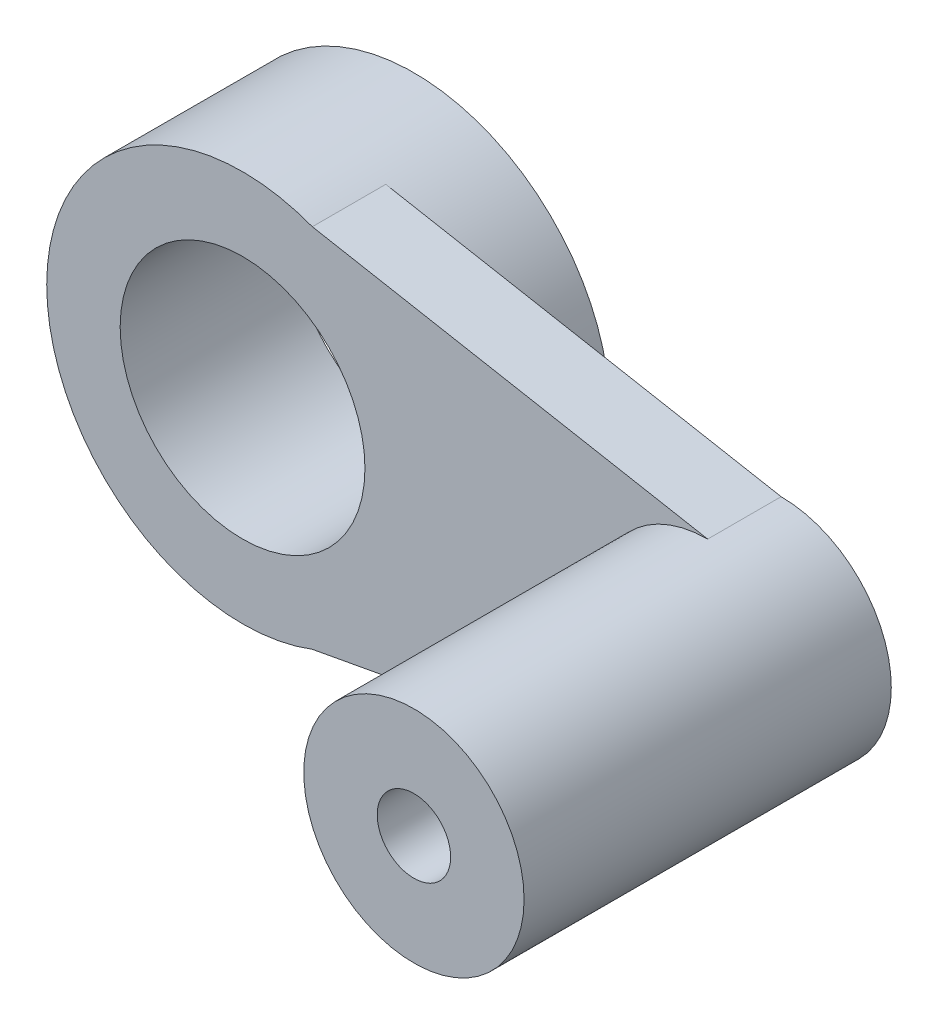
from build123d import *

# Parameters (mm, degrees)
SKETCH1_R           = 16
SKETCH1_R_2         = 10
BOSS_EXTRUDE1_DEPTH = 14
BOSS_EXTRUDE2_DEPTH = 6
SKETCH3_R           = 9
SKETCH3_R_2         = 3
BOSS_EXTRUDE3_DEPTH = 24
SKETCH4_R           = 9
SKETCH4_R_2         = 3
BOSS_EXTRUDE4_DEPTH = 6


with BuildPart() as part:
    # Sketch1 → Boss-Extrude1 (new body)
    with BuildSketch(Plane.XY):
        Circle(SKETCH1_R)
        Circle(SKETCH1_R_2, mode=Mode.SUBTRACT)
    extrude(amount=BOSS_EXTRUDE1_DEPTH)

    # Sketch2 → Boss-Extrude2 (add)
    with BuildSketch(Plane.XY.offset(14)):
        with BuildLine():
            ThreePointArc((38, -9), (29, 0), (38, 9))
            Line((38, 9), (5.701272605, 14.949765573))
            ThreePointArc((5.701272605, 14.949765573), (13.176121616, 9.07688378), (16, 0))
            ThreePointArc((16, 0), (13.176121616, -9.07688378), (5.701272605, -14.949765573))
            Line((5.701272605, -14.949765573), (38, -9))
        make_face()
    extrude(amount=-BOSS_EXTRUDE2_DEPTH)



with BuildPart() as body_2:
    # Sketch3 → Boss-Extrude3 (new body)
    with BuildSketch(Plane.XY.offset(14)):
        with Locations((38, 0)):
            Circle(SKETCH3_R)
        with Locations((38, 0)):
            Circle(SKETCH3_R_2, mode=Mode.SUBTRACT)
    extrude(amount=BOSS_EXTRUDE3_DEPTH)


with BuildPart() as part_1:
    add(part.part)

    add(body_2.part)  # Boss-Extrude4 merges body 2
    # Sketch4 → Boss-Extrude4 (add)
    with BuildSketch(Plane(origin=(0, 0, 14), x_dir=(-1, 0, 0), z_dir=(0, 0, -1))):
        with Locations((-38, 0)):
            Circle(SKETCH4_R)
        with Locations((-38, 0)):
            Circle(SKETCH4_R_2, mode=Mode.SUBTRACT)
    extrude(amount=BOSS_EXTRUDE4_DEPTH)


solid = part_1.part
